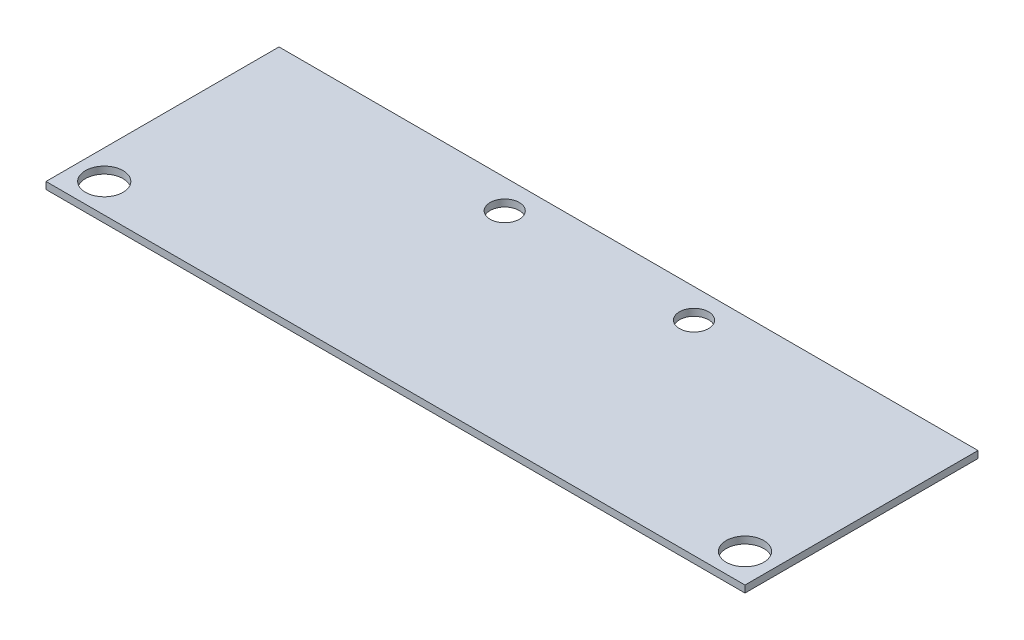
from build123d import *

# Parameters (mm, degrees)
BOSS_EXTRUDE1_DEPTH = 1.524
SKETCH2_R           = 4.1021
SKETCH2_R_2         = 3.175
CUT_EXTRUDE1_DEPTH  = 2.524


with BuildPart() as part:
    # Sketch1 → Boss-Extrude1 (new body)
    with BuildSketch(Plane(origin=(0, 0, 0), x_dir=(1, 0, 0), z_dir=(0, 1, 0))):
        Polygon((-50.221590033, -45.107739437), (102.178409967, -45.107739437), (102.178409967, 5.692260563), (51.378409967, 5.692260563), (0.578409967, 5.692260563), (-50.221590033, 5.692260563), align=None)
    extrude(amount=BOSS_EXTRUDE1_DEPTH)

    # Sketch2 → Cut-Extrude1 (cut, through all)
    with BuildSketch(Plane(origin=(0, 1.524, 0), x_dir=(1, 0, 0), z_dir=(0, 1, 0))):
        with Locations((-43.871590033, -38.757739437)):
            Circle(SKETCH2_R)
        with Locations((95.828409967, -38.757739437)):
            Circle(SKETCH2_R)
        with Locations((46.615909967, -0.657739437)):
            Circle(SKETCH2_R_2)
        with Locations((5.340909967, -0.657739437)):
            Circle(SKETCH2_R_2)
    extrude(amount=-CUT_EXTRUDE1_DEPTH, mode=Mode.SUBTRACT)


solid = part.part
